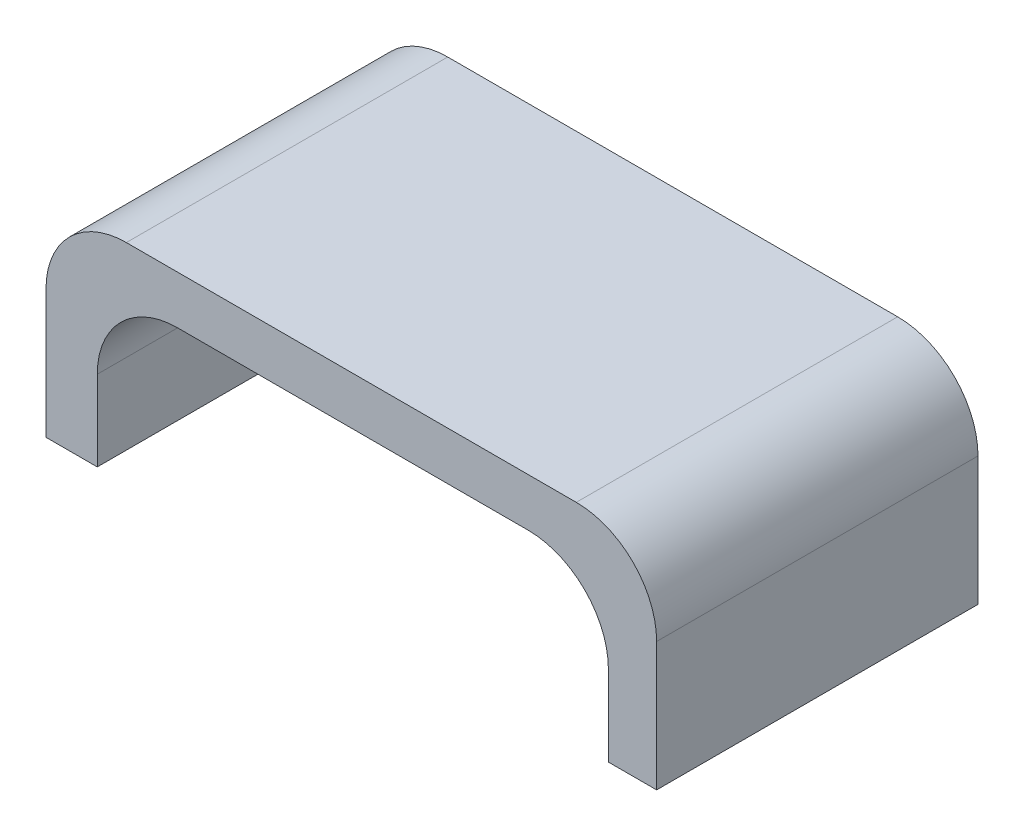
from build123d import *

# Parameters (mm, degrees)
EXTRUDE_1_DEPTH = 40


with BuildPart() as part:
    # 草图1 → 凸台-拉伸1 (new body)
    with BuildSketch(Plane.XY):
        with BuildLine():
            Line((-37.999999813, 14.005326892), (-37.999999813, 20.009487218))
            Line((-37.999999813, 20.009487218), (-37.999999813, 30))
            ThreePointArc((-37.999999813, 30), (-35.071067625, 37.071067812), (-27.999999813, 40))
            Line((-27.999999813, 40), (28, 40))
            ThreePointArc((28, 40), (35.071067812, 37.071067812), (38, 30))
            Line((38, 30), (38, 20))
            Line((38, 20), (38, 14))
            Line((38, 14), (32, 14))
            Line((32, 14), (32, 24))
            ThreePointArc((32, 24), (29.071067812, 31.071067812), (22, 34))
            Line((22, 34), (-21.616055892, 34))
            ThreePointArc((-21.616055892, 34), (-28.687123704, 31.071067812), (-31.616055892, 24))
            Line((-31.616055892, 24), (-31.616055892, 14.005326892))
            Line((-31.616055892, 14.005326892), (-37.999999813, 14.005326892))
        make_face()
    extrude(amount=EXTRUDE_1_DEPTH)


solid = part.part
